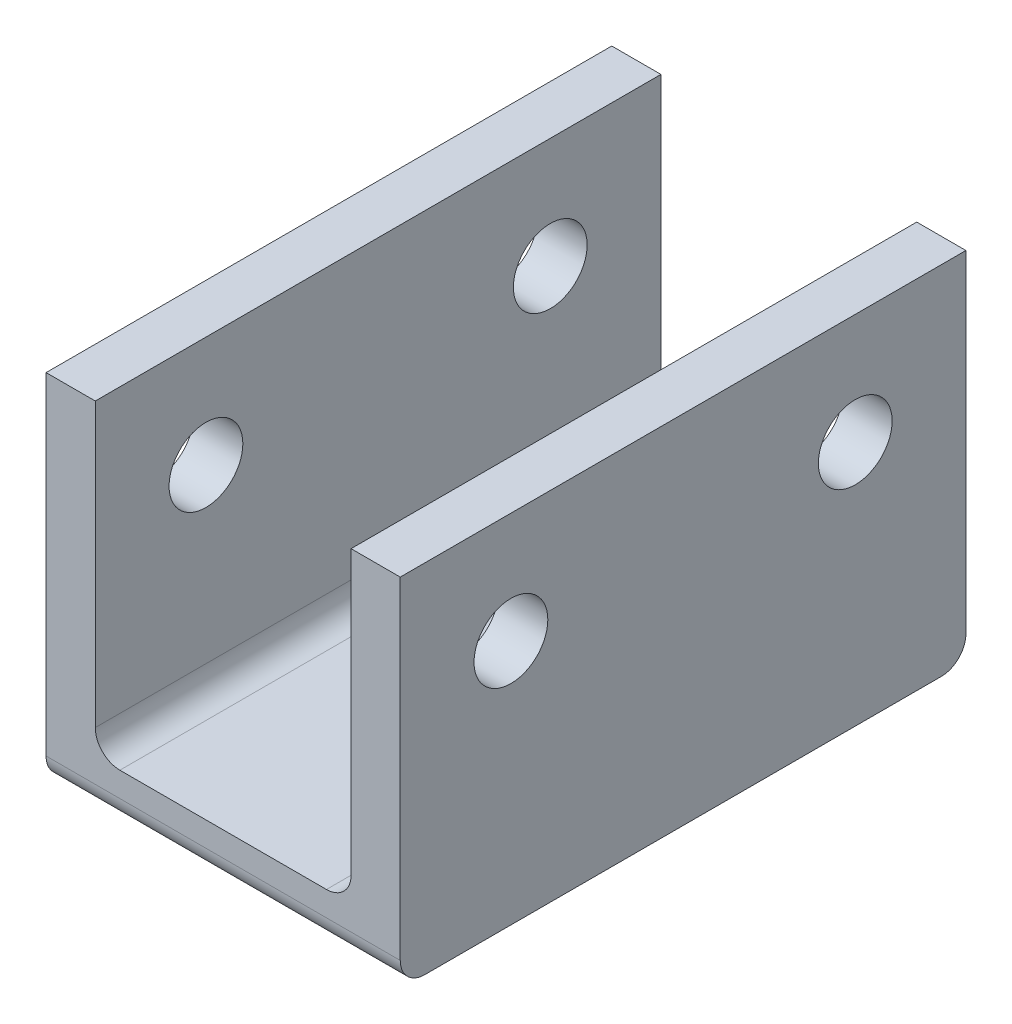
from build123d import *

# Parameters (mm, degrees)
BOSS_EXTRUDE1_DEPTH     = 11.5
SKETCH2_R               = 1.5
CUT_EXTRUDE1_DEPTH      = 1
CUT_EXTRUDE1_DEPTH_BACK = 15.4
FILLET1_R               = 1
FILLET2_R               = 1


with BuildPart() as part:
    # Sketch1 → Boss-Extrude1 (new body, symmetric)
    with BuildSketch(Plane.XY):
        Polygon((-5.2, 1), (5.2, 1), (5.2, 13.5), (7.2, 13.5), (7.2, -1), (-7.2, -1), (-7.2, 13.5), (-5.2, 13.5), align=None)
    extrude(amount=BOSS_EXTRUDE1_DEPTH, both=True)

    # Sketch2 → Cut-Extrude1 (cut, two sides)
    with BuildSketch(Plane(origin=(7.2, 0, 0), x_dir=(0, 0, -1), z_dir=(1, 0, 0))) as cut_extrude1_sk:
        with Locations((-7, 9)):
            Circle(SKETCH2_R)
        with Locations((7, 9)):
            Circle(SKETCH2_R)
    extrude(amount=CUT_EXTRUDE1_DEPTH, mode=Mode.SUBTRACT)
    extrude(cut_extrude1_sk.sketch, amount=-CUT_EXTRUDE1_DEPTH_BACK, mode=Mode.SUBTRACT)

    # Fillet1
    fillet1_edges = [part.edges().sort_by_distance(p)[0] for p in [
        (0, -1, -11.5),
        (0, -1, 11.5),
    ]]
    fillet(fillet1_edges, radius=FILLET1_R)

    # Fillet2
    fillet2_edges = [part.edges().sort_by_distance(p)[0] for p in [
        (-5.2, 1, 0),
        (5.2, 1, 0),
    ]]
    fillet(fillet2_edges, radius=FILLET2_R)


solid = part.part
